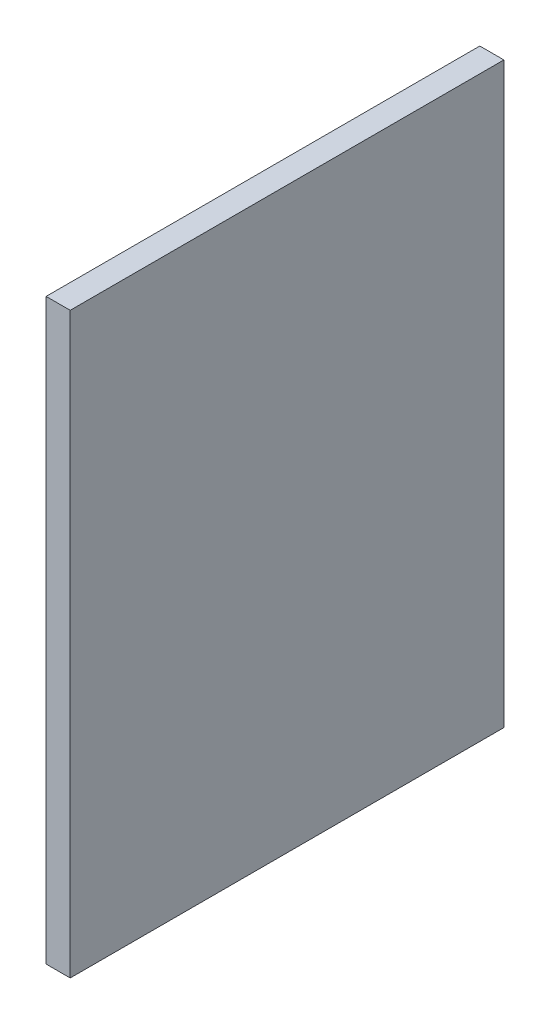
from build123d import *

# Parameters (mm, degrees)
SKETCH1_W           = 57.15
SKETCH1_H           = 76.2
BOSS_EXTRUDE1_DEPTH = 1.5875


with BuildPart() as part:
    # Sketch1 → Boss-Extrude1 (new body, symmetric)
    with BuildSketch(Plane(origin=(0, 0, 0), x_dir=(0, 0, -1), z_dir=(1, 0, 0))):
        Rectangle(SKETCH1_W, SKETCH1_H)
    extrude(amount=BOSS_EXTRUDE1_DEPTH, both=True)


solid = part.part
